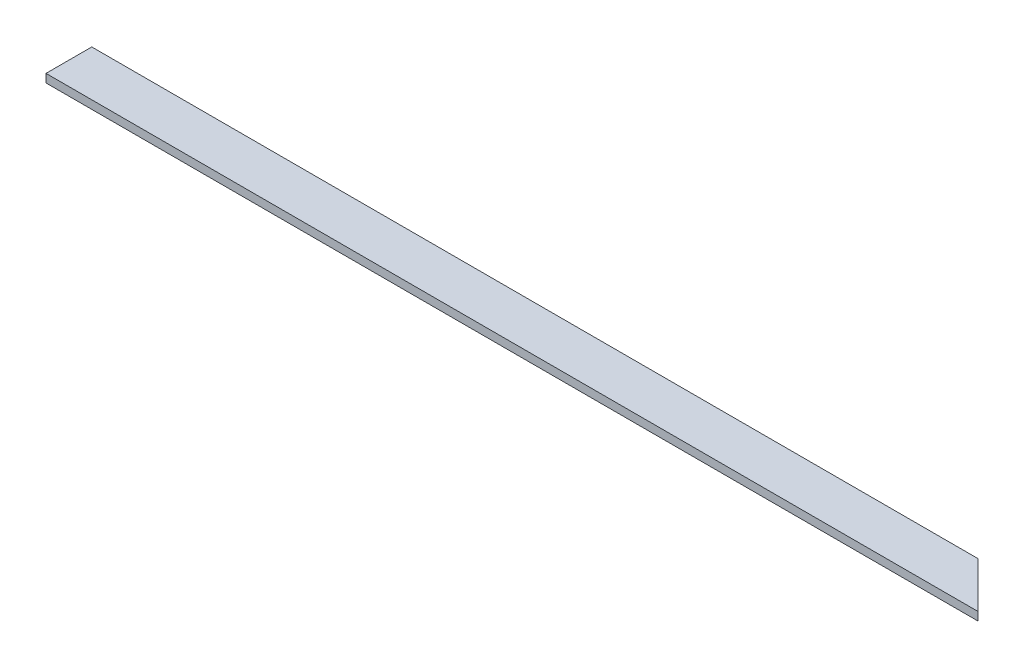
from build123d import *

# Parameters (mm, degrees)
BOSS_EXTRUDE1_DEPTH = 25.4


with BuildPart() as part:
    # Sketch1 → Boss-Extrude1 (new body)
    with BuildSketch(Plane(origin=(0, 0, 0), x_dir=(1, 0, 0), z_dir=(0, 1, 0))):
        Polygon((0, 139.7), (0, 0), (2705.1, 0), (2844.8, 0), (2705.1, 139.7), align=None)
    extrude(amount=BOSS_EXTRUDE1_DEPTH)


solid = part.part
